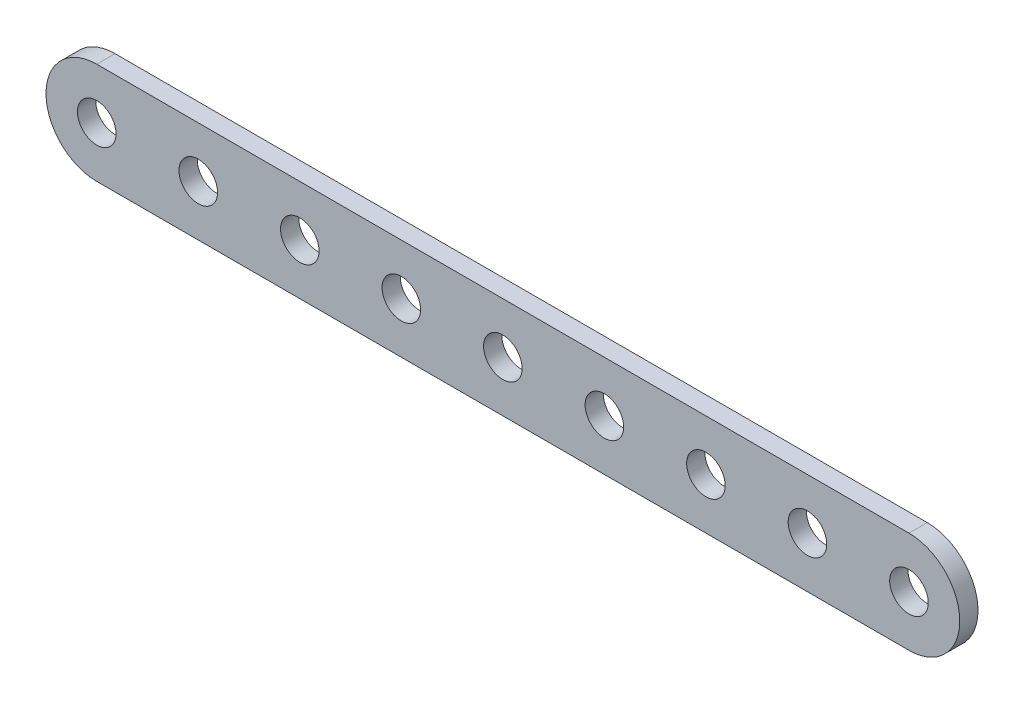
from build123d import *

# Parameters (mm, degrees)
BOSS_EXTRUDE1_DEPTH = 2.286
SKETCH2_R           = 2.413
CUT_EXTRUDE1_DEPTH  = 3.286
LPATTERN1_COUNT     = 9
LPATTERN1_PITCH     = 12.7


with BuildPart() as part:
    # Sketch1 → Boss-Extrude1 (new body)
    with BuildSketch(Plane.XY):
        with BuildLine():
            Line((-50.8, 6.35), (50.8, 6.35))
            ThreePointArc((50.8, 6.35), (57.15, 0), (50.8, -6.35))
            Line((50.8, -6.35), (-50.8, -6.35))
            ThreePointArc((-50.8, -6.35), (-57.15, 0), (-50.8, 6.35))
        make_face()
    extrude(amount=BOSS_EXTRUDE1_DEPTH)

    # Sketch2 → Cut-Extrude1 (cut, through all)
    with BuildSketch(Plane.XY.offset(2.286)):
        with Locations((-50.8, 0)):
            Circle(SKETCH2_R)
    cut_extrude1 = extrude(amount=-CUT_EXTRUDE1_DEPTH, mode=Mode.SUBTRACT)

    # LPattern1: Cut-Extrude1 ×9
    with Locations(*[(i * LPATTERN1_PITCH, 0, 0) for i in range(1, LPATTERN1_COUNT)]):
        add(cut_extrude1, mode=Mode.SUBTRACT)


solid = part.part
